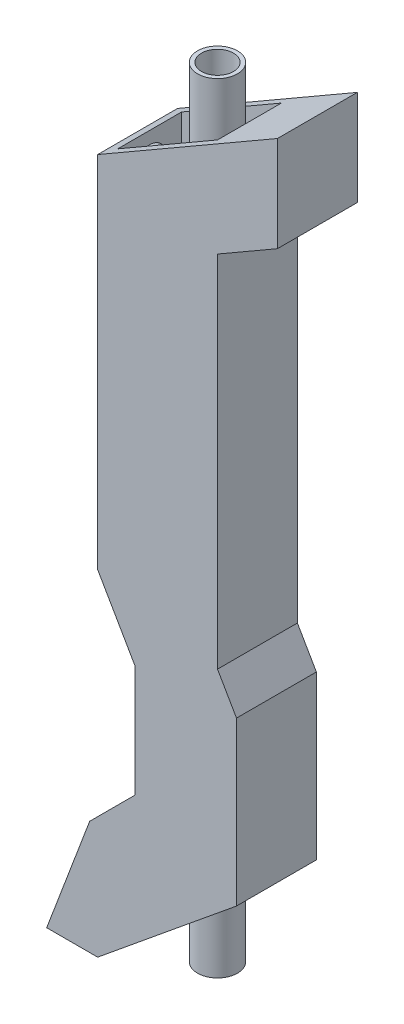
from build123d import *

# Parameters (mm, degrees)
BOSS_EXTRUDE1_DEPTH      = 10
SKETCH4_W                = 25
SKETCH4_H                = 16
CUT_EXTRUDE1_DEPTH       = 20
CUT_EXTRUDE1_DEPTH_BACK  = 89
SKETCH5_R                = 5
BOSS_EXTRUDE2_DEPTH      = 25
BOSS_EXTRUDE2_DEPTH_BACK = 10
SKETCH7_R                = 4
BOSS_EXTRUDE3_DEPTH      = 10
BOSS_EXTRUDE3_DEPTH_BACK = 18
SKETCH8_R                = 4
CUT_EXTRUDE2_DEPTH       = 25
SKETCH9_W                = 24
SKETCH9_H                = 17
CUT_EXTRUDE3_DEPTH       = 32
CUT_EXTRUDE3_DEPTH_BACK  = 28
SKETCH11_R               = 5
SKETCH11_R_2             = 4
BOSS_EXTRUDE4_DEPTH      = 10
BOSS_EXTRUDE4_DEPTH_BACK = 30


with BuildPart() as part:
    # Sketch2 → Boss-Extrude1 (new body, symmetric)
    with BuildSketch(Plane.XY):
        Polygon((25, 102.091511477), (25, 125.980762114), (-20, 100), (-20, 10), (-10.629510425, -6.230164035), (-10.629510425, -34.17760788), (-22.002554237, -45.550651692), (-32.764034249, -74.019237886), (-20, -74.019237886), (14.753991307, -45.550651692), (14.753991307, -4.802897042), (10, 3.431257439), (10, 93.431257439), align=None)
    extrude(amount=BOSS_EXTRUDE1_DEPTH, both=True)

    # Sketch4 → Cut-Extrude1 (cut, two sides)
    with BuildSketch(Plane(origin=(0, 100, 0), x_dir=(1, 0, 0), z_dir=(0, 1, 0))) as cut_extrude1_sk:
        with Locations((-4.5, 0)):
            Rectangle(SKETCH4_W, SKETCH4_H)
    extrude(amount=CUT_EXTRUDE1_DEPTH, mode=Mode.SUBTRACT)
    extrude(cut_extrude1_sk.sketch, amount=-CUT_EXTRUDE1_DEPTH_BACK, mode=Mode.SUBTRACT)



with BuildPart() as body_2:
    # Sketch5 → Boss-Extrude2 (new body, two sides)
    with BuildSketch(Plane(origin=(0, 100, 0), x_dir=(1, 0, 0), z_dir=(0, 1, 0))) as boss_extrude2_sk:
        Circle(SKETCH5_R)
    extrude(amount=BOSS_EXTRUDE2_DEPTH)
    extrude(boss_extrude2_sk.sketch, amount=-BOSS_EXTRUDE2_DEPTH_BACK)


with BuildPart() as part_1:
    add(part.part)

    add(body_2.part)  # Boss-Extrude3 merges body 2
    # Sketch7 → Boss-Extrude3 (add, two sides)
    with BuildSketch(Plane(origin=(0, 0, 0), x_dir=(0, 0, -1), z_dir=(1, 0, 0))) as boss_extrude3_sk:
        with Locations((0, 94.619147456)):
            Circle(SKETCH7_R)
    extrude(amount=BOSS_EXTRUDE3_DEPTH)
    extrude(boss_extrude3_sk.sketch, amount=-BOSS_EXTRUDE3_DEPTH_BACK)

    # Sketch8 → Cut-Extrude2 (cut)
    with BuildSketch(Plane(origin=(0, 125, 0), x_dir=(1, 0, 0), z_dir=(0, 1, 0))):
        Circle(SKETCH8_R)
    extrude(amount=-CUT_EXTRUDE2_DEPTH, mode=Mode.SUBTRACT)

    # Sketch9 → Cut-Extrude3 (cut, two sides)
    with BuildSketch(Plane(origin=(0, -40, 0), x_dir=(1, 0, 0), z_dir=(0, 1, 0))) as cut_extrude3_sk:
        with Locations((1.532719755, -0.006367264)):
            Rectangle(SKETCH9_W, SKETCH9_H)
    extrude(amount=CUT_EXTRUDE3_DEPTH, mode=Mode.SUBTRACT)
    extrude(cut_extrude3_sk.sketch, amount=-CUT_EXTRUDE3_DEPTH_BACK, mode=Mode.SUBTRACT)


with BuildPart() as body_2_2:
    # Sketch11 → Boss-Extrude4 (new body, two sides)
    with BuildSketch(Plane(origin=(0, -40, 0), x_dir=(1, 0, 0), z_dir=(0, 1, 0))) as boss_extrude4_sk:
        Circle(SKETCH11_R)
        Circle(SKETCH11_R_2, mode=Mode.SUBTRACT)
    extrude(amount=BOSS_EXTRUDE4_DEPTH)
    extrude(boss_extrude4_sk.sketch, amount=-BOSS_EXTRUDE4_DEPTH_BACK)


solid = Compound([part_1.part, body_2_2.part])
